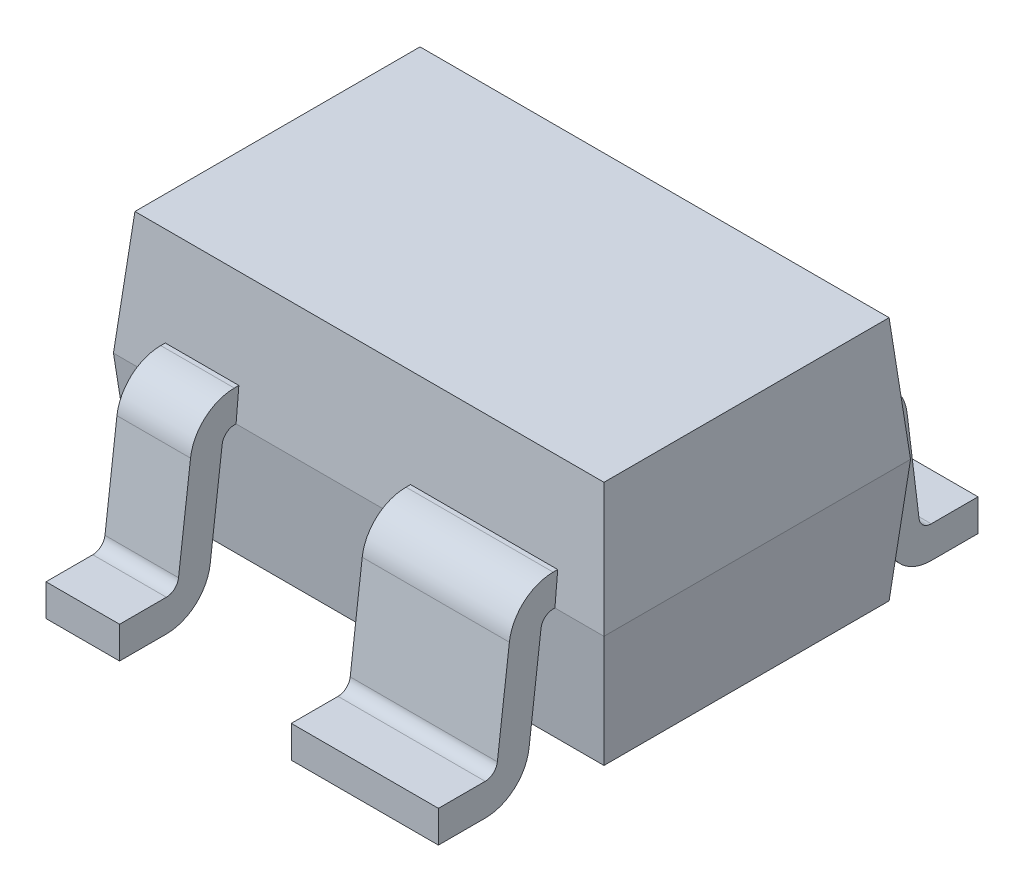
from build123d import *

# Parameters (mm, degrees)
SKETCH1_W                = 2
SKETCH1_H                = 1.25
EXTRUDE1_DEPTH           = 0.5
EXTRUDE1_TAPER           = 5
EXTRUDE1_OTHER_WAY_DEPTH = 0.5
EXTRUDE1_OTHER_WAY_TAPER = 5
EXTRUDE2_START           = 0.5
EXTRUDE2_DEPTH           = 0.3
EXTRUDE2_DEPTH_BACK      = 0.3
EXTRUDE3_START           = 0.65
EXTRUDE3_DEPTH           = 0.15
FILLET1_R                = 0.05
FILLET2_R                = 0.18


with BuildPart() as part:
    # Sketch1 → Extrude1 (new body)
    with BuildSketch(Plane(origin=(0, 0, 0), x_dir=(1, 0, 0), z_dir=(0, 1, 0))):
        Rectangle(SKETCH1_W, SKETCH1_H)
    extrude(amount=EXTRUDE1_DEPTH, taper=EXTRUDE1_TAPER)

    # Sketch1 → Extrude1 other way (add)
    with BuildSketch(Plane(origin=(0, 0, 0), x_dir=(1, 0, 0), z_dir=(0, 1, 0))):
        Rectangle(SKETCH1_W, SKETCH1_H)
    extrude(amount=-EXTRUDE1_OTHER_WAY_DEPTH, taper=EXTRUDE1_OTHER_WAY_TAPER)

    # Sketch2 → Extrude2 (add, two sides)
    with BuildSketch(Plane(origin=(0, 0, 0), x_dir=(0, 0, -1), z_dir=(1, 0, 0)).offset(EXTRUDE2_START)) as extrude2_sk:
        Polygon((-0.613626474, 0.13), (-0.791343548, 0.13), (-0.865014284, -0.47), (-1.1, -0.47), (-1.1, -0.6), (-0.75, -0.6), (-0.676329263, 0), (-0.613626474, 0), align=None)
    extrude(amount=EXTRUDE2_DEPTH)
    extrude(extrude2_sk.sketch, amount=-EXTRUDE2_DEPTH_BACK)

    # Sketch2_3 → Extrude3 (add, symmetric)
    with BuildSketch(Plane(origin=(0, 0, 0), x_dir=(0, 0, -1), z_dir=(1, 0, 0)).offset(EXTRUDE3_START)):
        Polygon((0.613626474, 0.13), (0.791343548, 0.13), (0.865014284, -0.47), (1.1, -0.47), (1.1, -0.6), (0.75, -0.6), (0.676329263, 0), (0.613626474, 0), align=None)
        Polygon((-0.791343548, 0.13), (-0.865014284, -0.47), (-1.1, -0.47), (-1.1, -0.6), (-0.75, -0.6), (-0.676329263, 0), (-0.613626474, 0), (-0.613626474, 0.13), align=None)
    extrude3 = extrude(amount=EXTRUDE3_DEPTH, both=True)

    # Mirror1: Extrude3 across plane
    add(extrude3.mirror(Plane(origin=(0, 0, 0), x_dir=(0, 0, 1), z_dir=(1, 0, 0))))

    # Fillet1
    fillet1_edges = [part.edges().sort_by_distance(p)[0] for p in [
        (-0.65, -0.47, -0.865014284),
        (-0.65, 0, -0.676329263),
        (-0.65, 0, 0.676329263),
        (-0.65, -0.47, 0.865014284),
        (0.5, -0.47, 0.865014284),
        (0.5, 0, 0.676329263),
        (0.65, 0, -0.676329263),
        (0.65, -0.47, -0.865014284),
    ]]
    fillet(fillet1_edges, radius=FILLET1_R)

    # Fillet2
    fillet2_edges = [part.edges().sort_by_distance(p)[0] for p in [
        (-0.65, 0.13, -0.791343548),
        (-0.65, -0.6, -0.75),
        (-0.65, 0.13, 0.791343548),
        (-0.65, -0.6, 0.75),
        (0.5, 0.13, 0.791343548),
        (0.5, -0.6, 0.75),
        (0.65, 0.13, -0.791343548),
        (0.65, -0.6, -0.75),
    ]]
    fillet(fillet2_edges, radius=FILLET2_R)


solid = part.part
